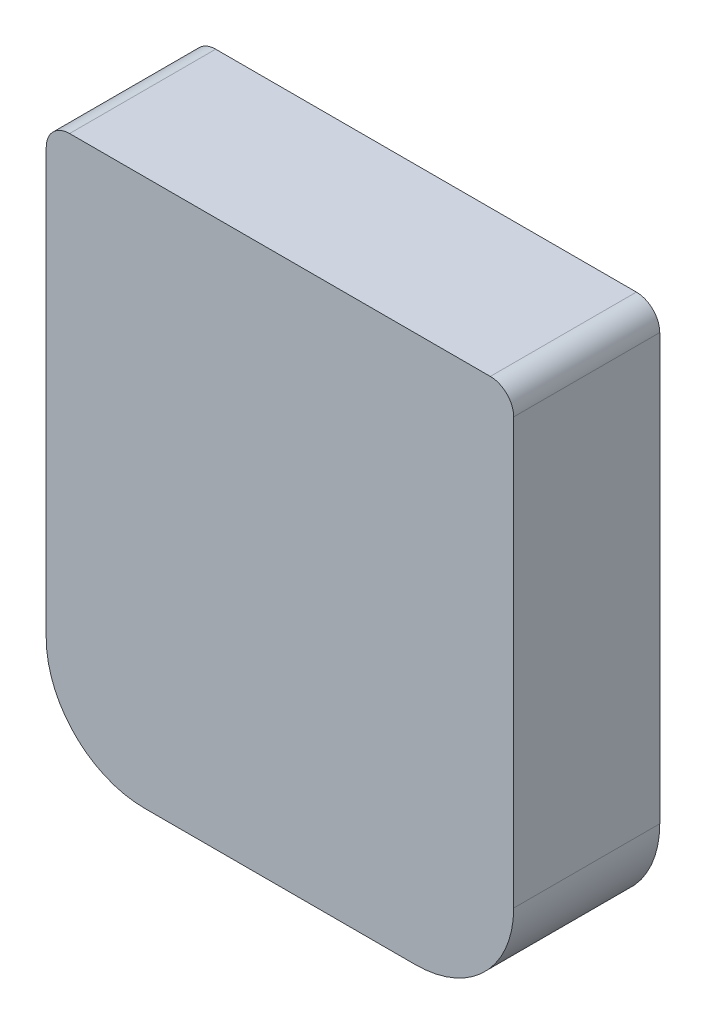
from build123d import *

# Parameters (mm, degrees)
SKETCH1_W           = 10
SKETCH1_H           = 11.7
BOSS_EXTRUDE1_DEPTH = 3.125
FILLET1_R           = 2.1
FILLET2_R           = 0.5


with BuildPart() as part:
    # Sketch1 → Boss-Extrude1 (new body)
    with BuildSketch(Plane.XY):
        with Locations((0, -0.95)):
            Rectangle(SKETCH1_W, SKETCH1_H)
    extrude(amount=BOSS_EXTRUDE1_DEPTH)

    # Fillet1
    fillet1_edges = [part.edges().sort_by_distance(p)[0] for p in [
        (5, -6.8, 1.5625),
        (-5, -6.8, 1.5625),
    ]]
    fillet(fillet1_edges, radius=FILLET1_R)

    # Fillet2
    fillet2_edges = [part.edges().sort_by_distance(p)[0] for p in [
        (-5, 4.9, 1.5625),
        (5, 4.9, 1.5625),
    ]]
    fillet(fillet2_edges, radius=FILLET2_R)


solid = part.part
